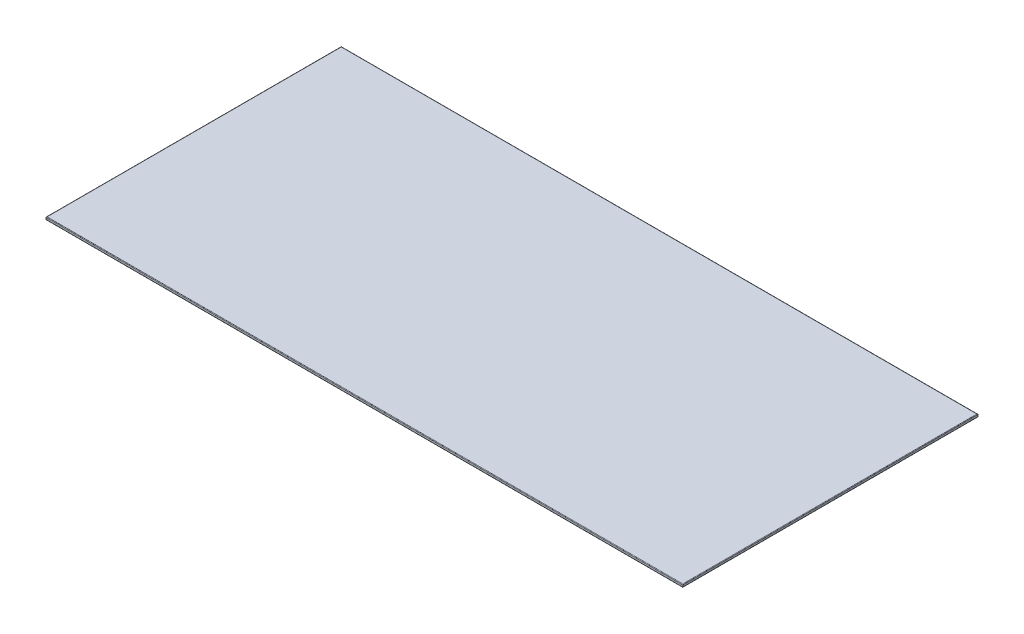
from build123d import *

# Parameters (mm, degrees)
SKETCH1_W           = 1156
SKETCH1_H           = 536
BOSS_EXTRUDE1_DEPTH = 5
FILLET1_R           = 1


with BuildPart() as part:
    # Sketch1 → Boss-Extrude1 (new body)
    with BuildSketch(Plane(origin=(0, 0, 0), x_dir=(1, 0, 0), z_dir=(0, 1, 0))):
        Rectangle(SKETCH1_W, SKETCH1_H)
    extrude(amount=BOSS_EXTRUDE1_DEPTH)

    # Fillet1
    fillet1_edges = [part.edges().sort_by_distance(p)[0] for p in [
        (-578, 5, 0),
        (0, 5, 268),
        (578, 5, 0),
        (0, 0, 268),
        (-578, 0, 0),
        (0, 0, -268),
        (578, 0, 0),
        (0, 5, -268),
    ]]
    fillet(fillet1_edges, radius=FILLET1_R)


solid = part.part
